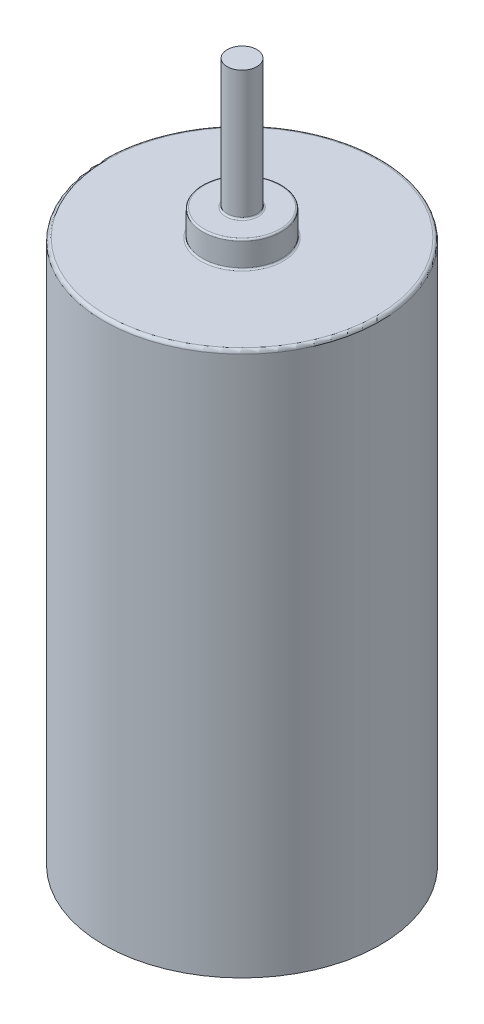
from build123d import *

# Parameters (mm, degrees)
SKETCH1_R           = 4.2
BOSS_EXTRUDE1_DEPTH = 16.51
SKETCH2_R           = 1.2
BOSS_EXTRUDE2_DEPTH = 0.8
SKETCH3_R           = 0.45
BOSS_EXTRUDE3_DEPTH = 3.92
FILLET3_R           = 0.05
FILLET4_R           = 0.1


with BuildPart() as part:
    # Sketch1 → Boss-Extrude1 (new body)
    with BuildSketch(Plane(origin=(0, 0, 0), x_dir=(1, 0, 0), z_dir=(0, 1, 0))):
        Circle(SKETCH1_R)
    extrude(amount=BOSS_EXTRUDE1_DEPTH)

    # Sketch2 → Boss-Extrude2 (add)
    with BuildSketch(Plane(origin=(0, 16.51, 0), x_dir=(1, 0, 0), z_dir=(0, 1, 0))):
        Circle(SKETCH2_R)
    extrude(amount=BOSS_EXTRUDE2_DEPTH)

    # Sketch3 → Boss-Extrude3 (add)
    with BuildSketch(Plane(origin=(0, 17.31, 0), x_dir=(1, 0, 0), z_dir=(0, 1, 0))):
        Circle(SKETCH3_R)
    extrude(amount=BOSS_EXTRUDE3_DEPTH)

    # Fillet3
    fillet3_edges = [part.edges().sort_by_distance(p)[0] for p in [
        (-0.45, 17.31, 0),
        (-1.2, 16.51, 0),
        (-1.2, 17.31, 0),
    ]]
    fillet(fillet3_edges, radius=FILLET3_R)

    # Fillet4
    fillet4_edges = [part.edges().sort_by_distance(p)[0] for p in [
        (-4.2, 16.51, 0),
    ]]
    fillet(fillet4_edges, radius=FILLET4_R)


solid = part.part
